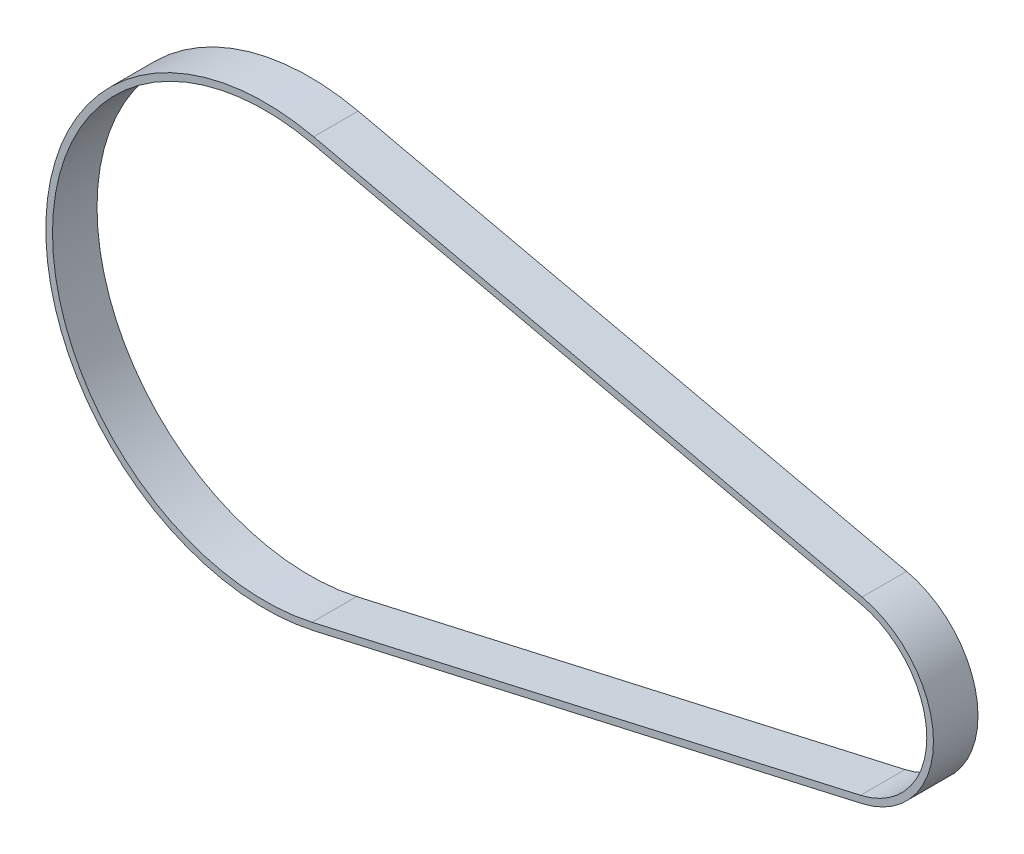
from build123d import *

# Parameters (mm, degrees)
EXTRUDE_1_DEPTH = 10


with BuildPart() as part:
    # 草圖1 → 伸長1 (new body)
    with BuildSketch(Plane.XY):
        with BuildLine():
            Line((-53.857158108, 48.025160286), (69.306656371, 20.089720822))
            ThreePointArc((69.306656371, 20.089720822), (85.35, 0), (69.306656371, -20.089720822))
            Line((69.306656371, -20.089720822), (-53.857158108, -48.025160286))
            ThreePointArc((-53.857158108, -48.025160286), (-113.995, 0), (-53.857158108, 48.025160286))
        make_face()
        with BuildLine():
            Line((-54.188953475, 46.562316537), (68.974861004, 18.626877073))
            ThreePointArc((68.974861004, 18.626877073), (83.85, 0), (68.974861004, -18.626877073))
            Line((68.974861004, -18.626877073), (-54.188953475, -46.562316537))
            ThreePointArc((-54.188953475, -46.562316537), (-112.495, 0), (-54.188953475, 46.562316537))
        make_face(mode=Mode.SUBTRACT)
    extrude(amount=EXTRUDE_1_DEPTH)


solid = part.part
